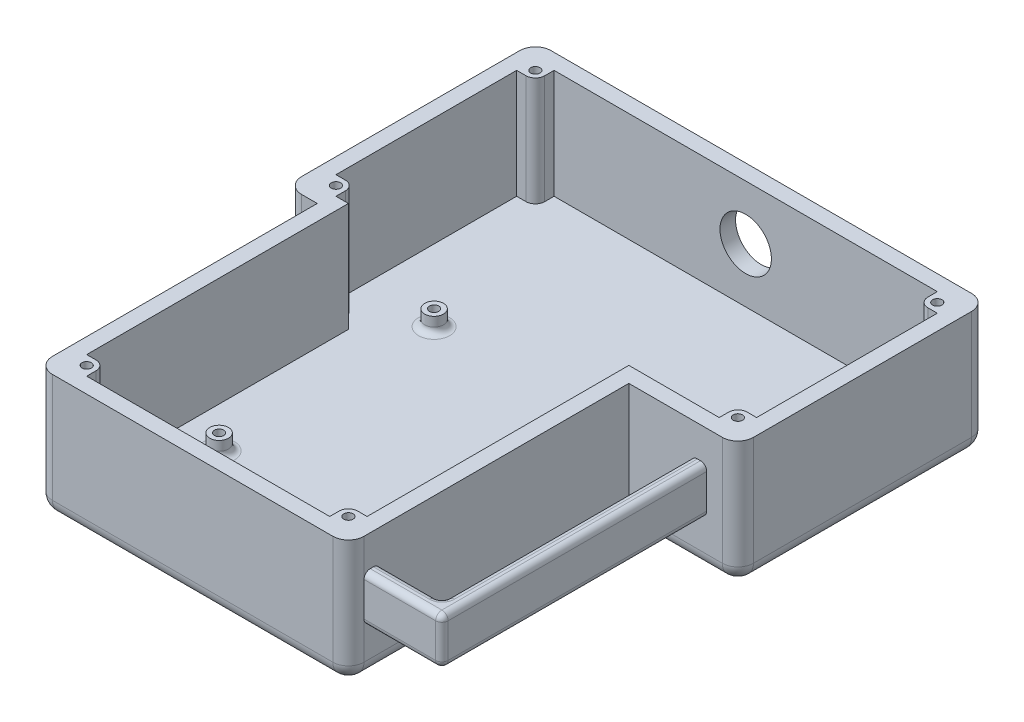
from build123d import *

# Parameters (mm, degrees)
BOSS_EXTRUDE1_DEPTH = 35
BOSS_EXTRUDE4_START = 5
SKETCH7_W           = 100
SKETCH7_H           = 90
BOSS_EXTRUDE4_DEPTH = 5
FILLET4_R           = 5
SKETCH8_R           = 1.5
BOSS_EXTRUDE5_DEPTH = 35
SKETCH9_R           = 3
SKETCH9_R_2         = 1.5
BOSS_EXTRUDE6_DEPTH = 5
FILLET5_R           = 2
SKETCH10_R          = 8.25
CUT_EXTRUDE1_DEPTH  = 10
SKETCH11_W          = 85
SKETCH11_H          = 15
BOSS_EXTRUDE7_DEPTH = 25
CUT_EXTRUDE2_REACH  = 156.11
SKETCH12_W          = 20
SKETCH12_H          = 80
FILLET6_R           = 2


with BuildPart() as part:
    # Sketch1 → Boss-Extrude1 (new body)
    with BuildSketch(Plane(origin=(0, 0, 0), x_dir=(1, 0, 0), z_dir=(0, 1, 0))):
        with BuildLine():
            Line((-60, 45), (-50, 45))
            Line((-50, 45), (-50, -45))
            Line((-50, -45), (50, -45))
            Line((50, -45), (50, 45))
            Line((50, 45), (60, 45))
            Line((60, 45), (80, 45))
            ThreePointArc((80, 45), (83.535533906, 46.464466094), (85, 50))
            Line((85, 50), (85, 120))
            ThreePointArc((85, 120), (83.535533906, 123.535533906), (80, 125))
            Line((80, 125), (60, 125))
            Line((60, 125), (-60, 125))
            Line((-60, 125), (-60, 45))
        make_face()
        Polygon((60, 50), (45, 50), (45, -40), (-45, -40), (-45, 50), (-55, 50), (-55, 120), (60, 120), (80, 120), (80, 50), align=None, mode=Mode.SUBTRACT)
    extrude(amount=BOSS_EXTRUDE1_DEPTH)

    # Sketch7 → Boss-Extrude4 (add)
    with BuildSketch(Plane.XZ.offset(BOSS_EXTRUDE4_START)):
        with BuildLine():
            Line((-60, -45), (80, -45))
            ThreePointArc((80, -45), (83.535533906, -46.464466094), (85, -50))
            Line((85, -50), (85, -120))
            ThreePointArc((85, -120), (83.535533906, -123.535533906), (80, -125))
            Line((80, -125), (-60, -125))
            Line((-60, -125), (-60, -45))
        make_face()
        Rectangle(SKETCH7_W, SKETCH7_H)
    extrude(amount=-BOSS_EXTRUDE4_DEPTH)

    # Fillet4
    fillet4_edges = [part.edges().sort_by_distance(p)[0] for p in [
        (-60, 15, -45),
        (-50, 15, 45),
        (50, 15, 45),
        (-60, 15, -125),
        (65, -5, -45),
        (83.535533906, -5, -46.464466094),
        (10, -5, -125),
        (83.535533906, -5, -123.535533906),
        (85, -5, -85),
        (-60, -5, -85),
        (-50, -5, 0),
        (0, -5, 45),
        (50, -5, 0),
    ]]
    fillet(fillet4_edges, radius=FILLET4_R)

    # Sketch8 → Boss-Extrude5 (add)
    # profile 1 of 6: a face of its own
    with BuildSketch(Plane(origin=(0, 0, 0), x_dir=(1, 0, 0), z_dir=(0, 1, 0))):
        with BuildLine():
            Line((-45, -40), (-39, -40))
            Line((-39, -40), (-39, -37))
            ThreePointArc((-39, -37), (-39.878679635, -34.878679678), (-41.999999938, -34))
            Line((-41.999999938, -34), (-45, -34))
            Line((-45, -34), (-45, -40))
        make_face()
        with Locations((-42, -37)):
            Circle(SKETCH8_R, mode=Mode.SUBTRACT)
    # profile 2 of 6: a face of its own
    with BuildSketch(Plane(origin=(0, 0, 0), x_dir=(1, 0, 0), z_dir=(0, 1, 0))):
        with BuildLine():
            Line((39, -37), (39, -40))
            Line((39, -40), (45, -40))
            Line((45, -40), (45, -34))
            Line((45, -34), (42, -34))
            ThreePointArc((42, -34), (39.878679656, -34.878679656), (39, -37))
        make_face()
        with Locations((42, -37)):
            Circle(SKETCH8_R, mode=Mode.SUBTRACT)
    # profile 3 of 6: a face of its own
    with BuildSketch(Plane(origin=(0, 0, 0), x_dir=(1, 0, 0), z_dir=(0, 1, 0))):
        with BuildLine():
            Line((-49, 50), (-49, 53))
            ThreePointArc((-49, 53), (-49.878679656, 55.121320344), (-52, 56))
            Line((-52, 56), (-55, 56))
            Line((-55, 56), (-55, 50))
            Line((-55, 50), (-49, 50))
        make_face()
        with Locations((-52, 53)):
            Circle(SKETCH8_R, mode=Mode.SUBTRACT)
    # profile 4 of 6: a face of its own
    with BuildSketch(Plane(origin=(0, 0, 0), x_dir=(1, 0, 0), z_dir=(0, 1, 0))):
        with BuildLine():
            Line((74, 53), (74, 50))
            Line((74, 50), (80, 50))
            Line((80, 50), (80, 56))
            Line((80, 56), (77, 56))
            ThreePointArc((77, 56), (74.878679656, 55.121320344), (74, 53))
        make_face()
        with Locations((77, 53)):
            Circle(SKETCH8_R, mode=Mode.SUBTRACT)
    # profile 5 of 6: a face of its own
    with BuildSketch(Plane(origin=(0, 0, 0), x_dir=(1, 0, 0), z_dir=(0, 1, 0))):
        with BuildLine():
            Line((-55, 114), (-52, 114))
            ThreePointArc((-52, 114), (-49.878679656, 114.878679656), (-49, 117))
            Line((-49, 117), (-49, 120))
            Line((-49, 120), (-55, 120))
            Line((-55, 120), (-55, 114))
        make_face()
        with Locations((-52, 117)):
            Circle(SKETCH8_R, mode=Mode.SUBTRACT)
    # profile 6 of 6: a face of its own
    with BuildSketch(Plane(origin=(0, 0, 0), x_dir=(1, 0, 0), z_dir=(0, 1, 0))):
        with BuildLine():
            Line((77, 114), (80, 114))
            Line((80, 114), (80, 120))
            Line((80, 120), (74, 120))
            Line((74, 120), (74, 117))
            ThreePointArc((74, 117), (74.878679656, 114.878679656), (77, 114))
        make_face()
        with Locations((77, 117)):
            Circle(SKETCH8_R, mode=Mode.SUBTRACT)
    extrude(amount=BOSS_EXTRUDE5_DEPTH)

    # Sketch9 → Boss-Extrude6 (add)
    # profile 1 of 4: a face of its own
    with BuildSketch(Plane(origin=(0, 0, 0), x_dir=(1, 0, 0), z_dir=(0, 1, 0))):
        with Locations((-32, 64.5)):
            Circle(SKETCH9_R)
        with Locations((-32, 64.5)):
            Circle(SKETCH9_R_2, mode=Mode.SUBTRACT)
    # profile 2 of 4: a face of its own
    with BuildSketch(Plane(origin=(0, 0, 0), x_dir=(1, 0, 0), z_dir=(0, 1, 0))):
        with Locations((32, 64.5)):
            Circle(SKETCH9_R)
        with Locations((32, 64.5)):
            Circle(SKETCH9_R_2, mode=Mode.SUBTRACT)
    # profile 3 of 4: a face of its own
    with BuildSketch(Plane(origin=(0, 0, 0), x_dir=(1, 0, 0), z_dir=(0, 1, 0))):
        with Locations((-32, -4.5)):
            Circle(SKETCH9_R)
        with Locations((-32, -4.5)):
            Circle(SKETCH9_R_2, mode=Mode.SUBTRACT)
    # profile 4 of 4: a face of its own
    with BuildSketch(Plane(origin=(0, 0, 0), x_dir=(1, 0, 0), z_dir=(0, 1, 0))):
        with Locations((32, -4.5)):
            Circle(SKETCH9_R)
        with Locations((32, -4.5)):
            Circle(SKETCH9_R_2, mode=Mode.SUBTRACT)
    extrude(amount=BOSS_EXTRUDE6_DEPTH)

    # Fillet5
    fillet5_edges = [part.edges().sort_by_distance(p)[0] for p in [
        (29, 0, 4.5),
        (-35, 0, 4.5),
        (29, 0, -64.5),
        (-35, 0, -64.5),
    ]]
    fillet(fillet5_edges, radius=FILLET5_R)

    # Sketch10 → Cut-Extrude1 (cut)
    with BuildSketch(Plane(origin=(0, 0, -125), x_dir=(-1, 0, 0), z_dir=(0, 0, -1))):
        with Locations((-12.5, 17.5)):
            Circle(SKETCH10_R)
    extrude(amount=-CUT_EXTRUDE1_DEPTH, mode=Mode.SUBTRACT)

    # Sketch11 → Boss-Extrude7 (add)
    with BuildSketch(Plane(origin=(50, 0, 0), x_dir=(0, 0, -1), z_dir=(1, 0, 0))):
        with Locations((2.5, 17.5)):
            Rectangle(SKETCH11_W, SKETCH11_H)
    extrude(amount=BOSS_EXTRUDE7_DEPTH)

    # Sketch12 → Cut-Extrude2 (cut, up to next)
    with BuildSketch(Plane(origin=(0, 25, 0), x_dir=(1, 0, 0), z_dir=(0, 1, 0)), mode=Mode.PRIVATE) as cut_extrude2_sk1:
        with Locations((60, 5)):
            Rectangle(SKETCH12_W, SKETCH12_H)
    cut_extrude2_tool1 = extrude(cut_extrude2_sk1.sketch, amount=-CUT_EXTRUDE2_REACH, mode=Mode.PRIVATE) & part.part
    add(cut_extrude2_tool1.solids().sort_by_distance((60, 25, -5))[0], mode=Mode.SUBTRACT)

    # Fillet6
    fillet6_edges = [part.edges().sort_by_distance(p)[0] for p in [
        (70, 10, -5),
        (60, 10, 35),
        (70, 17.5, 35),
        (70, 25, -5),
        (60, 25, 35),
        (75, 10, -2.5),
        (62.5, 10, 40),
        (75, 25, -2.5),
        (62.5, 25, 40),
        (75, 17.5, 40),
    ]]
    fillet(fillet6_edges, radius=FILLET6_R)


solid = part.part
